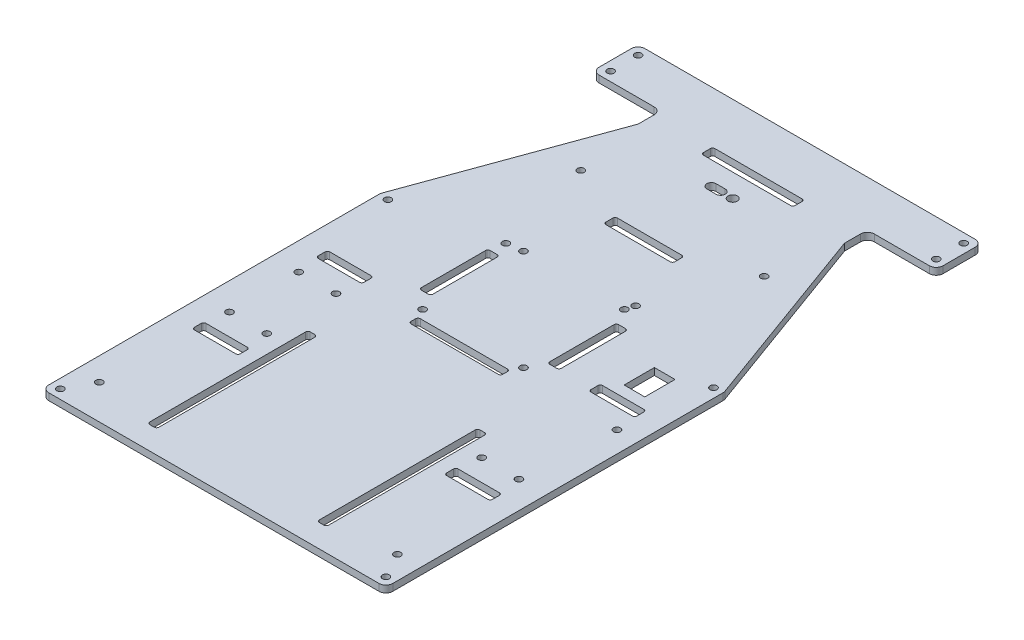
from build123d import *

# Parameters (mm, degrees)
SKETCH1_R           = 1.5
BOSS_EXTRUDE1_DEPTH = 3
SKETCH2_R           = 1.5
SKETCH2_R_2         = 2
SKETCH2_W           = 9
SKETCH2_H           = 13.2
CUT_EXTRUDE1_DEPTH  = 4
SKETCH3_R           = 1.5
CUT_EXTRUDE2_DEPTH  = 4


with BuildPart() as part:
    # Sketch1 → Boss-Extrude1 (new body)
    with BuildSketch(Plane(origin=(0, 0, 0), x_dir=(1, 0, 0), z_dir=(0, 1, 0))):
        with BuildLine():
            Line((-72, 110), (-48, 110))
            ThreePointArc((-48, 110), (-45.878679656, 109.121320344), (-45, 107))
            Line((-45, 107), (-45, 100))
            Line((-45, 100), (-74.819077862, 18.072756904))
            ThreePointArc((-74.819077862, 18.072756904), (-74.954423259, 17.567641007), (-75, 17.046696474))
            Line((-75, 17.046696474), (-75, -127))
            ThreePointArc((-75, -127), (-74.121320344, -129.121320344), (-72, -130))
            Line((-72, -130), (72, -130))
            ThreePointArc((72, -130), (74.121320344, -129.121320344), (75, -127))
            Line((75, -127), (75, 17.046696474))
            ThreePointArc((75, 17.046696474), (74.954423259, 17.567641007), (74.819077862, 18.072756904))
            Line((74.819077862, 18.072756904), (45, 100))
            Line((45, 100), (45, 107))
            ThreePointArc((45, 107), (45.878679656, 109.121320344), (48, 110))
            Line((48, 110), (72, 110))
            ThreePointArc((72, 110), (74.121320344, 110.878679656), (75, 113))
            Line((75, 113), (75, 127))
            ThreePointArc((75, 127), (74.121320344, 129.121320344), (72, 130))
            Line((72, 130), (-72, 130))
            ThreePointArc((-72, 130), (-74.121320344, 129.121320344), (-75, 127))
            Line((-75, 127), (-75, 113))
            ThreePointArc((-75, 113), (-74.121320344, 110.878679656), (-72, 110))
        make_face()
        with Locations((-71, -126)):
            Circle(SKETCH1_R, mode=Mode.SUBTRACT)
        with Locations((-71, 16.870369494)):
            Circle(SKETCH1_R, mode=Mode.SUBTRACT)
        with Locations((71, -126)):
            Circle(SKETCH1_R, mode=Mode.SUBTRACT)
        with Locations((71, 16.870369494)):
            Circle(SKETCH1_R, mode=Mode.SUBTRACT)
        with Locations((-71, 126)):
            Circle(SKETCH1_R, mode=Mode.SUBTRACT)
        with Locations((-71, 114)):
            Circle(SKETCH1_R, mode=Mode.SUBTRACT)
        with Locations((71, 114)):
            Circle(SKETCH1_R, mode=Mode.SUBTRACT)
        with Locations((71, 126)):
            Circle(SKETCH1_R, mode=Mode.SUBTRACT)
        with BuildLine():
            Line((19, 102.5), (-19, 102.5))
            ThreePointArc((-19, 102.5), (-19.707106781, 102.792893219), (-20, 103.5))
            Line((-20, 103.5), (-20, 106.5))
            ThreePointArc((-20, 106.5), (-19.707106781, 107.207106781), (-19, 107.5))
            Line((-19, 107.5), (19, 107.5))
            ThreePointArc((19, 107.5), (19.707106781, 107.207106781), (20, 106.5))
            Line((20, 106.5), (20, 103.5))
            ThreePointArc((20, 103.5), (19.707106781, 102.792893219), (19, 102.5))
        make_face(mode=Mode.SUBTRACT)
    extrude(amount=BOSS_EXTRUDE1_DEPTH)

    # Sketch2 → Cut-Extrude1 (cut)
    with BuildSketch(Plane(origin=(0, 3, 0), x_dir=(1, 0, 0), z_dir=(0, 1, 0))):
        with Locations((-46.875, -60.1)):
            Circle(SKETCH2_R)
        with Locations((-63.125, -29.9)):
            Circle(SKETCH2_R)
        with Locations((-63.125, -60.1)):
            Circle(SKETCH2_R)
        with Locations((-46.875, -29.9)):
            Circle(SKETCH2_R)
        with Locations((22, 27)):
            Circle(SKETCH2_R)
        with Locations((22, -17)):
            Circle(SKETCH2_R)
        with Locations((-22, -17)):
            Circle(SKETCH2_R)
        with Locations((-22, 27)):
            Circle(SKETCH2_R)
        with Locations((65, -115)):
            Circle(SKETCH2_R)
        with Locations((-65, -115)):
            Circle(SKETCH2_R)
        with Locations((3.75, 92.5)):
            Circle(SKETCH2_R_2)
        with Locations((63.125, -60.1)):
            Circle(SKETCH2_R)
        with Locations((46.875, -60.1)):
            Circle(SKETCH2_R)
        with Locations((65.875, -20.1)):
            Circle(SKETCH2_R)
        with BuildLine():
            Line((64, -11.5), (46, -11.5))
            ThreePointArc((46, -11.5), (45.292893219, -11.207106781), (45, -10.5))
            Line((45, -10.5), (45, -7.5))
            ThreePointArc((45, -7.5), (45.292893219, -6.792893219), (46, -6.5))
            Line((46, -6.5), (64, -6.5))
            ThreePointArc((64, -6.5), (64.707106781, -6.792893219), (65, -7.5))
            Line((65, -7.5), (65, -10.5))
            ThreePointArc((65, -10.5), (64.707106781, -11.207106781), (64, -11.5))
        make_face()
        with Locations((55, 5)):
            Rectangle(SKETCH2_W, SKETCH2_H)
        with BuildLine():
            Line((-64, -15.5), (-46, -15.5))
            ThreePointArc((-46, -15.5), (-45.292893219, -15.792893219), (-45, -16.5))
            Line((-45, -16.5), (-45, -19.5))
            ThreePointArc((-45, -19.5), (-45.292893219, -20.207106781), (-46, -20.5))
            Line((-46, -20.5), (-64, -20.5))
            ThreePointArc((-64, -20.5), (-64.707106781, -20.207106781), (-65, -19.5))
            Line((-65, -19.5), (-65, -16.5))
            ThreePointArc((-65, -16.5), (-64.707106781, -15.792893219), (-64, -15.5))
        make_face()
        with BuildLine():
            Line((-45, -73.5), (-45, -70.5))
            ThreePointArc((-45, -70.5), (-45.292893219, -69.792893219), (-46, -69.5))
            Line((-46, -69.5), (-64, -69.5))
            ThreePointArc((-64, -69.5), (-64.707106781, -69.792893219), (-65, -70.5))
            Line((-65, -70.5), (-65, -73.5))
            ThreePointArc((-65, -73.5), (-64.707106781, -74.207106781), (-64, -74.5))
            Line((-64, -74.5), (-46, -74.5))
            ThreePointArc((-46, -74.5), (-45.292893219, -74.207106781), (-45, -73.5))
        make_face()
        with BuildLine():
            Line((38, -50), (36, -50))
            ThreePointArc((36, -50), (35.292893219, -50.292893219), (35, -51))
            Line((35, -51), (35, -119))
            ThreePointArc((35, -119), (35.292893219, -119.707106781), (36, -120))
            Line((36, -120), (38, -120))
            ThreePointArc((38, -120), (38.707106781, -119.707106781), (39, -119))
            Line((39, -119), (39, -51))
            ThreePointArc((39, -51), (38.707106781, -50.292893219), (38, -50))
        make_face()
        with BuildLine():
            Line((-35, -51), (-35, -119))
            ThreePointArc((-35, -119), (-35.292893219, -119.707106781), (-36, -120))
            Line((-36, -120), (-38, -120))
            ThreePointArc((-38, -120), (-38.707106781, -119.707106781), (-39, -119))
            Line((-39, -119), (-39, -51))
            ThreePointArc((-39, -51), (-38.707106781, -50.292893219), (-38, -50))
            Line((-38, -50), (-36, -50))
            ThreePointArc((-36, -50), (-35.292893219, -50.292893219), (-35, -51))
        make_face()
        with BuildLine():
            Line((-5.5, 94.5), (-1.5, 94.5))
            ThreePointArc((-1.5, 94.5), (0.5, 92.5), (-1.5, 90.5))
            Line((-1.5, 90.5), (-5.5, 90.5))
            ThreePointArc((-5.5, 90.5), (-7.5, 92.5), (-5.5, 94.5))
        make_face()
        with BuildLine():
            Line((-14, 60), (14, 60))
            ThreePointArc((14, 60), (14.707106781, 59.707106781), (15, 59))
            Line((15, 59), (15, 56))
            ThreePointArc((15, 56), (14.707106781, 55.292893219), (14, 55))
            Line((14, 55), (-14, 55))
            ThreePointArc((-14, 55), (-14.707106781, 55.292893219), (-15, 56))
            Line((-15, 56), (-15, 59))
            ThreePointArc((-15, 59), (-14.707106781, 59.707106781), (-14, 60))
        make_face()
        with BuildLine():
            Line((29.5, -10), (26.5, -10))
            ThreePointArc((26.5, -10), (25.792893219, -9.707106781), (25.5, -9))
            Line((25.5, -9), (25.5, 19))
            ThreePointArc((25.5, 19), (25.792893219, 19.707106781), (26.5, 20))
            Line((26.5, 20), (29.5, 20))
            ThreePointArc((29.5, 20), (30.207106781, 19.707106781), (30.5, 19))
            Line((30.5, 19), (30.5, -9))
            ThreePointArc((30.5, -9), (30.207106781, -9.707106781), (29.5, -10))
        make_face()
        with BuildLine():
            Line((-29.5, 20), (-26.5, 20))
            ThreePointArc((-26.5, 20), (-25.792893219, 19.707106781), (-25.5, 19))
            Line((-25.5, 19), (-25.5, -9))
            ThreePointArc((-25.5, -9), (-25.792893219, -9.707106781), (-26.5, -10))
            Line((-26.5, -10), (-29.5, -10))
            ThreePointArc((-29.5, -10), (-30.207106781, -9.707106781), (-30.5, -9))
            Line((-30.5, -9), (-30.5, 19))
            ThreePointArc((-30.5, 19), (-30.207106781, 19.707106781), (-29.5, 20))
        make_face()
        with BuildLine():
            Line((64, -74.5), (46, -74.5))
            ThreePointArc((46, -74.5), (45.292893219, -74.207106781), (45, -73.5))
            Line((45, -73.5), (45, -70.5))
            ThreePointArc((45, -70.5), (45.292893219, -69.792893219), (46, -69.5))
            Line((46, -69.5), (64, -69.5))
            ThreePointArc((64, -69.5), (64.707106781, -69.792893219), (65, -70.5))
            Line((65, -70.5), (65, -73.5))
            ThreePointArc((65, -73.5), (64.707106781, -74.207106781), (64, -74.5))
        make_face()
    extrude(amount=-CUT_EXTRUDE1_DEPTH, mode=Mode.SUBTRACT)

    # Sketch3 → Cut-Extrude2 (cut)
    with BuildSketch(Plane(origin=(0, 3, 0), x_dir=(1, 0, 0), z_dir=(0, 1, 0))):
        with Locations((23.1, 30.81)):
            Circle(SKETCH3_R)
        with Locations((-28.8, 26.11)):
            Circle(SKETCH3_R)
        with Locations((22, -17)):
            Circle(SKETCH3_R)
        with Locations((-40, 70)):
            Circle(SKETCH3_R)
        with Locations((40, 70)):
            Circle(SKETCH3_R)
        with BuildLine():
            Line((-19, -21), (19, -21))
            ThreePointArc((19, -21), (19.707106781, -21.292893219), (20, -22))
            Line((20, -22), (20, -24))
            ThreePointArc((20, -24), (19.707106781, -24.707106781), (19, -25))
            Line((19, -25), (-19, -25))
            ThreePointArc((-19, -25), (-19.707106781, -24.707106781), (-20, -24))
            Line((-20, -24), (-20, -22))
            ThreePointArc((-20, -22), (-19.707106781, -21.292893219), (-19, -21))
        make_face()
    extrude(amount=-CUT_EXTRUDE2_DEPTH, mode=Mode.SUBTRACT)


solid = part.part
